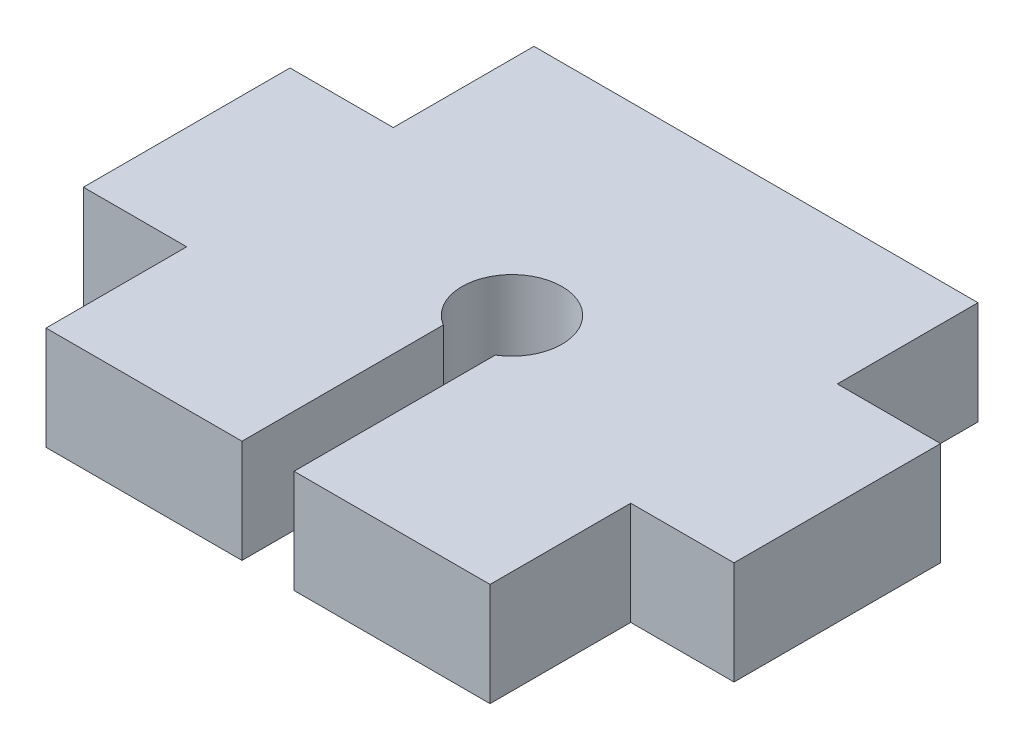
from build123d import *

# Parameters (mm, degrees)
SKETCH2_W           = 27.3
SKETCH2_H           = 30
BOSS_EXTRUDE1_DEPTH = 6.35
SKETCH3_W           = 12.7
SKETCH3_H           = 6.35
BOSS_EXTRUDE2_DEPTH = 6.35
SKETCH4_R           = 3.075
CUT_EXTRUDE1_DEPTH  = 7.35
CUT_EXTRUDE2_REACH  = 32
SKETCH5_W           = 3.2
SKETCH5_H           = 6.35


with BuildPart() as part:
    # Sketch2 → Boss-Extrude1 (new body)
    with BuildSketch(Plane(origin=(0, 0, 0), x_dir=(1, 0, 0), z_dir=(0, 1, 0))):
        Rectangle(SKETCH2_W, SKETCH2_H)
    extrude(amount=BOSS_EXTRUDE1_DEPTH)

    # Sketch3 → Boss-Extrude2 (add)
    with BuildSketch(Plane(origin=(13.65, 0, 0), x_dir=(0, 0, -1), z_dir=(1, 0, 0))):
        with Locations((0, 3.175)):
            Rectangle(SKETCH3_W, SKETCH3_H)
    boss_extrude2 = extrude(amount=BOSS_EXTRUDE2_DEPTH)

    # Mirror1: Boss-Extrude2 across plane
    add(boss_extrude2.mirror(Plane(origin=(0, 0, 0), x_dir=(0, 0, 1), z_dir=(1, 0, 0))))

    # Sketch4 → Cut-Extrude1 (cut, through all)
    with BuildSketch(Plane(origin=(0, 6.35, 0), x_dir=(1, 0, 0), z_dir=(0, 1, 0))):
        Circle(SKETCH4_R)
    extrude(amount=-CUT_EXTRUDE1_DEPTH, mode=Mode.SUBTRACT)

    # Sketch5 → Cut-Extrude2 (cut, up to next)
    with BuildSketch(Plane.XY.offset(15), mode=Mode.PRIVATE) as cut_extrude2_sk1:
        with Locations((0, 3.175)):
            Rectangle(SKETCH5_W, SKETCH5_H)
    cut_extrude2_tool1 = extrude(cut_extrude2_sk1.sketch, amount=-CUT_EXTRUDE2_REACH, mode=Mode.PRIVATE) & part.part
    add(cut_extrude2_tool1.solids().sort_by_distance((0, 3.175, 15))[0], mode=Mode.SUBTRACT)


solid = part.part
